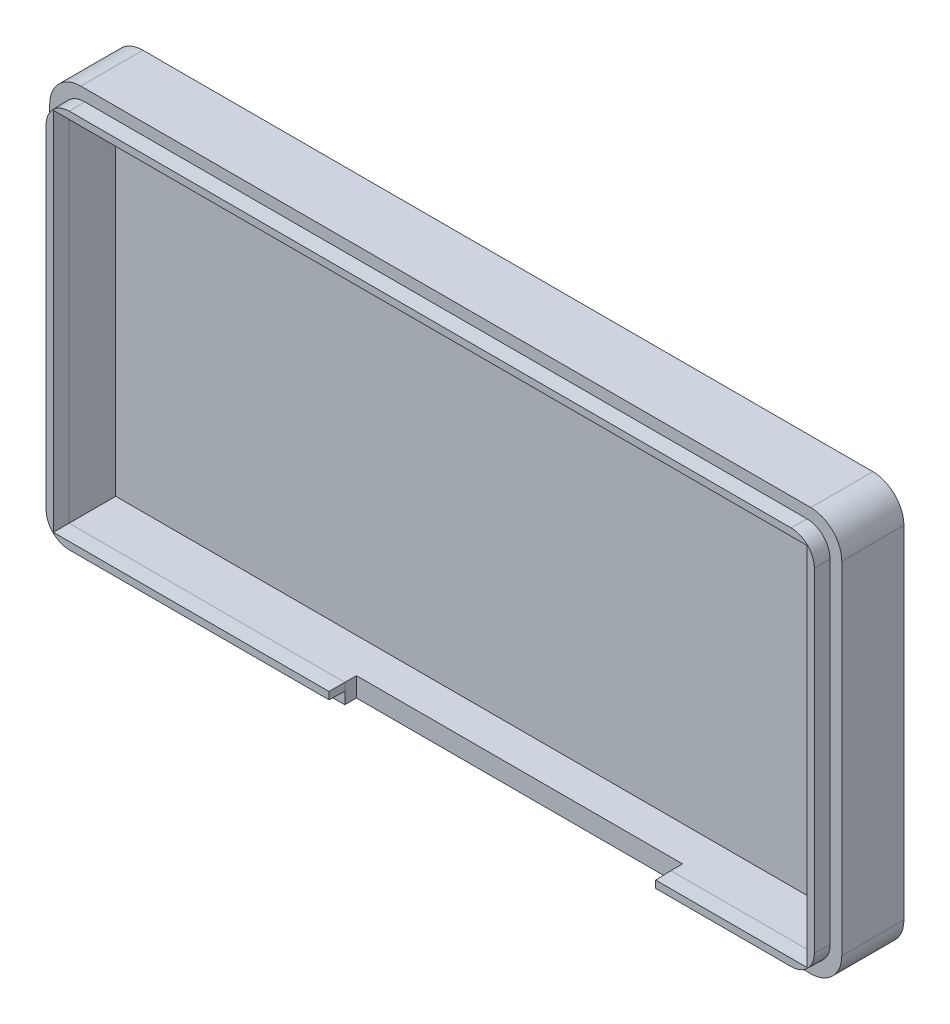
from build123d import *

# Parameters (mm, degrees)
ESQUISSE1_W             = 102
ESQUISSE1_H             = 52
BOSS_EXTRU_1_DEPTH      = 2
ESQUISSE2_W             = 102
ESQUISSE2_H             = 52
ESQUISSE2_W_2           = 97
ESQUISSE2_H_2           = 47
EXTRU_MINCE1_DEPTH      = 6
CONG_2_R                = 4
ESQUISSE4_W             = 42
ESQUISSE4_H             = 22.824396381
ENL_V_MAT_EXTRU_1_DEPTH = 14
EXTRU_MINCE2_DEPTH      = 2
EXTRU_MINCE2_DRAFT      = 1
CONG_3_R                = 3


with BuildPart() as part:
    # Esquisse1 → Boss.-Extru.1 (new body)
    with BuildSketch(Plane.XY):
        with Locations((51, 26)):
            Rectangle(ESQUISSE1_W, ESQUISSE1_H)
    extrude(amount=BOSS_EXTRU_1_DEPTH)

    # Esquisse2 → Extru.-Mince1 (add)
    with BuildSketch(Plane.XY.offset(2)):
        with Locations((51, 26)):
            Rectangle(ESQUISSE2_W, ESQUISSE2_H)
        with Locations((51, 26)):
            Rectangle(ESQUISSE2_W_2, ESQUISSE2_H_2, mode=Mode.SUBTRACT)
    extrude(amount=EXTRU_MINCE1_DEPTH)

    # Congé2
    cong_2_edges = [part.edges().sort_by_distance(p)[0] for p in [
        (0, 52, 4),
        (102, 52, 4),
        (102, 0, 4),
        (0, 0, 4),
    ]]
    fillet(cong_2_edges, radius=CONG_2_R)

    # Esquisse4 → Enlèv. mat.-Extru.1 (cut)
    with BuildSketch(Plane(origin=(0, 0, 0), x_dir=(1, 0, 0), z_dir=(0, 1, 0))):
        with Locations((59, -17.91219819)):
            Rectangle(ESQUISSE4_W, ESQUISSE4_H)
    extrude(amount=ENL_V_MAT_EXTRU_1_DEPTH, mode=Mode.SUBTRACT)


with BuildPart() as extru_mince2_tool:
    # Esquisse5 → Extru.-Mince2 (with draft: the straight prism first)
    with BuildSketch(Plane.XY.offset(8)):
        Polygon((38, 2.5), (2.5, 2.5), (2.5, 49.5), (99.5, 49.5), (99.5, 2.5), (80, 2.5), (80, 1.5), (100.5, 1.5), (100.5, 50.5), (1.5, 50.5), (1.5, 1.5), (38, 1.5), align=None)
    extrude(amount=EXTRU_MINCE2_DEPTH)
    # Extru.-Mince2: the draft: its side faces are tilted about the plane it starts from
    extru_mince2_sides = [extru_mince2_tool.faces().sort_by_distance(p)[0] for p in [
        (20.25, 2.5, 9),
        (2.5, 26, 9),
        (51, 49.5, 9),
        (99.5, 26, 9),
        (89.75, 2.5, 9),
        (80, 2, 9),
        (90.25, 1.5, 9),
        (100.5, 26, 9),
        (51, 50.5, 9),
        (1.5, 26, 9),
        (19.75, 1.5, 9),
        (38, 2, 9),
    ]]
    draft(extru_mince2_sides, Plane.XY.offset(8), EXTRU_MINCE2_DRAFT)


with BuildPart() as part_1:
    add(part.part)

    # Extru.-Mince2: add extru_mince2_tool
    add(extru_mince2_tool.part)

    # Congé3
    cong_3_edges = [part_1.edges().sort_by_distance(p)[0] for p in [
        (100.482544935, 1.517455065, 9),
        (100.482544935, 50.482544935, 9),
        (1.517455065, 50.482544935, 9),
        (1.517455065, 1.517455065, 9),
    ]]
    fillet(cong_3_edges, radius=CONG_3_R)


solid = part_1.part
